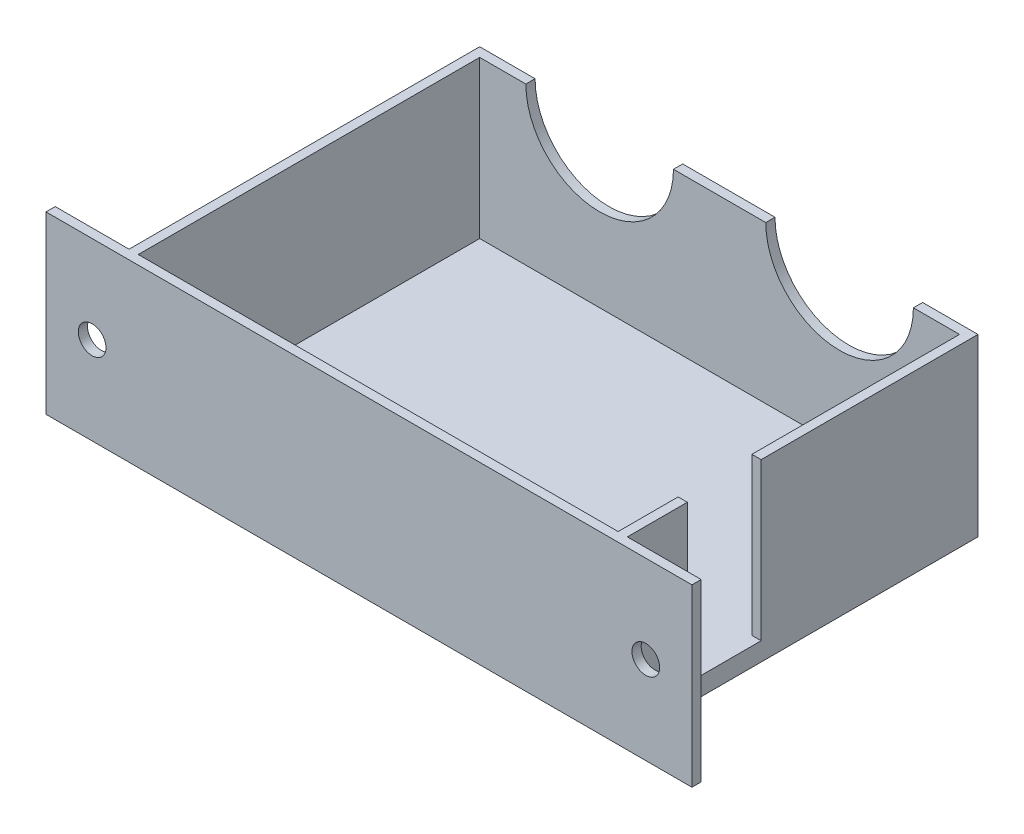
from build123d import *

# Parameters (mm, degrees)
SKETCH1_W           = 52
SKETCH1_H           = 37
BOSS_EXTRUDE1_DEPTH = 19
CUT_EXTRUDE1_REACH  = 41
SKETCH2_R           = 1.5
SKETCH3_W           = 52
SKETCH3_H           = 37
BOSS_EXTRUDE2_DEPTH = 2
CUT_EXTRUDE2_REACH  = 41
SKETCH4_R           = 8
SKETCH5_W           = 8
SKETCH5_H           = 17
CUT_EXTRUDE3_DEPTH  = 1


with BuildPart() as part:
    # Sketch1 → Boss-Extrude1 (new body)
    with BuildSketch(Plane(origin=(0, 0, 0), x_dir=(1, 0, 0), z_dir=(0, 1, 0))):
        Polygon((54, 0), (62, 0), (62, 1), (54, 1), (54, 39), (0, 39), (0, 1), (-8, 1), (-8, 0), (0, 0), align=None)
        with Locations((27, 19.5)):
            Rectangle(SKETCH1_W, SKETCH1_H, mode=Mode.SUBTRACT)
    extrude(amount=BOSS_EXTRUDE1_DEPTH)

    # Sketch2 → Cut-Extrude1 (cut, up to next)
    with BuildSketch(Plane.XY, mode=Mode.PRIVATE) as cut_extrude1_sk1:
        with Locations((-3, 9.5)):
            Circle(SKETCH2_R)
    cut_extrude1_tool1 = extrude(cut_extrude1_sk1.sketch, amount=-CUT_EXTRUDE1_REACH, mode=Mode.PRIVATE) & part.part
    add(cut_extrude1_tool1.solids().sort_by_distance((-3, 9.5, 0))[0], mode=Mode.SUBTRACT)
    # Sketch2 → Cut-Extrude1 (cut, up to next)
    with BuildSketch(Plane.XY, mode=Mode.PRIVATE) as cut_extrude1_sk2:
        with Locations((57, 9.5)):
            Circle(SKETCH2_R)
    cut_extrude1_tool2 = extrude(cut_extrude1_sk2.sketch, amount=-CUT_EXTRUDE1_REACH, mode=Mode.PRIVATE) & part.part
    add(cut_extrude1_tool2.solids().sort_by_distance((57, 9.5, 0))[0], mode=Mode.SUBTRACT)

    # Sketch3 → Boss-Extrude2 (add)
    with BuildSketch(Plane(origin=(0, 0, 0), x_dir=(1, 0, 0), z_dir=(0, 1, 0))):
        with Locations((27, 19.5)):
            Rectangle(SKETCH3_W, SKETCH3_H)
    extrude(amount=BOSS_EXTRUDE2_DEPTH)

    # Sketch4 → Cut-Extrude2 (cut, up to next)
    with BuildSketch(Plane(origin=(0, 0, -39), x_dir=(-1, 0, 0), z_dir=(0, 0, -1)), mode=Mode.PRIVATE) as cut_extrude2_sk1:
        with Locations((-14, 19)):
            Circle(SKETCH4_R)
    cut_extrude2_tool1 = extrude(cut_extrude2_sk1.sketch, amount=-CUT_EXTRUDE2_REACH, mode=Mode.PRIVATE) & part.part
    add(cut_extrude2_tool1.solids().sort_by_distance((14, 19, -39))[0], mode=Mode.SUBTRACT)
    # Sketch4 → Cut-Extrude2 (cut, up to next)
    with BuildSketch(Plane(origin=(0, 0, -39), x_dir=(-1, 0, 0), z_dir=(0, 0, -1)), mode=Mode.PRIVATE) as cut_extrude2_sk2:
        with Locations((-40, 19)):
            Circle(SKETCH4_R)
    cut_extrude2_tool2 = extrude(cut_extrude2_sk2.sketch, amount=-CUT_EXTRUDE2_REACH, mode=Mode.PRIVATE) & part.part
    add(cut_extrude2_tool2.solids().sort_by_distance((40, 19, -39))[0], mode=Mode.SUBTRACT)

    # Sketch5 → Cut-Extrude3 (cut)
    with BuildSketch(Plane(origin=(54, 0, 0), x_dir=(0, 0, -1), z_dir=(1, 0, 0))):
        with Locations((11.5, 10.5)):
            Rectangle(SKETCH5_W, SKETCH5_H)
    extrude(amount=-CUT_EXTRUDE3_DEPTH, mode=Mode.SUBTRACT)


solid = part.part
